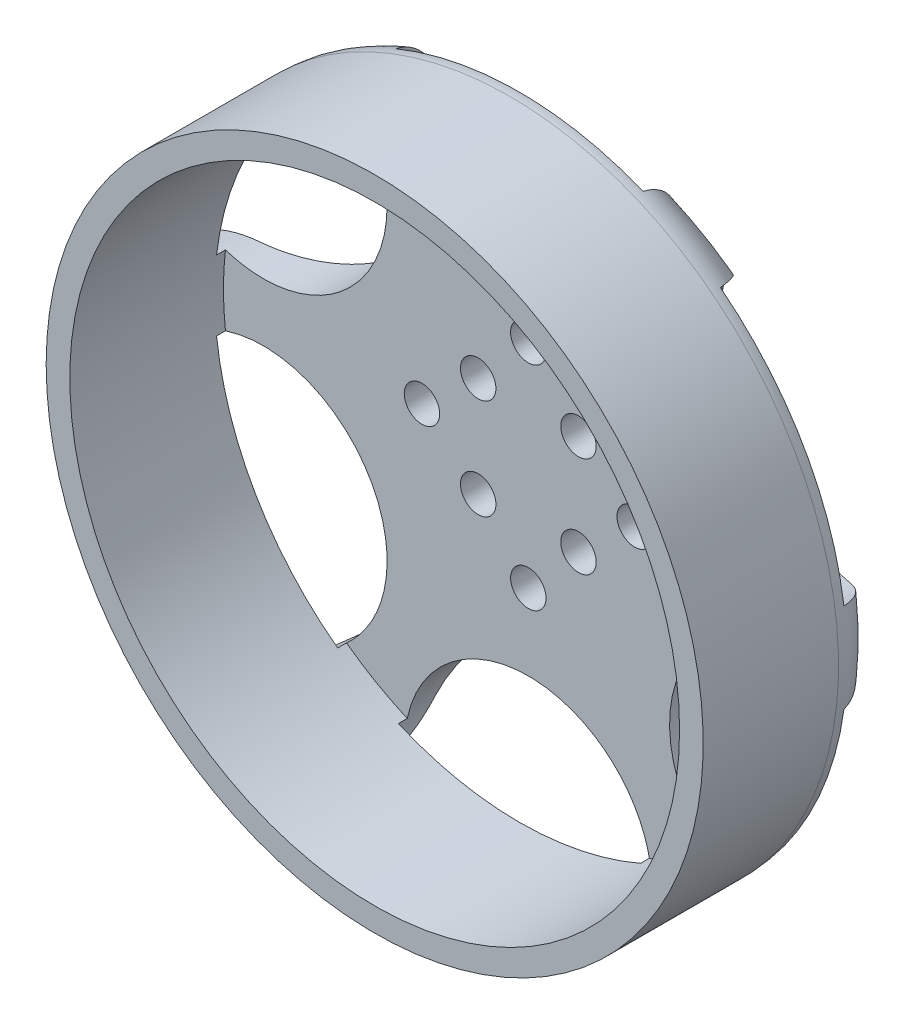
from build123d import *

# Parameters (mm, degrees)
SKETCH3_R          = 1.5
CUT_EXTRUDE1_DEPTH = 19.75
CIRPATTERN1_COUNT  = 4
CHAMFER1_SIZE      = 4.5
CHAMFER1_SIZE2     = 12.363648388
FILLET1_R          = 4
SKETCH4_R          = 25.8
CUT_EXTRUDE2_DEPTH = 13
SKETCH5_RX         = 10.458805078
SKETCH5_RY         = 10.321237489
CUT_EXTRUDE3_DEPTH = 6.5
CIRPATTERN2_COUNT  = 6


with BuildPart() as part:
    # Sketch2 → Revolve1 (revolve)
    with BuildSketch(Plane(origin=(0, 0, 0), x_dir=(1, 0, 0), z_dir=(0, 1, 0))):
        Polygon((0, 32), (-2, 32), (-2, 27), (-27.8, 27), (-27.8, 8.25), (0, 8.25), align=None)
    revolve(axis=Axis((0, 0, -88.99), (0, 0, 1)))

    # Sketch3 → Cut-Extrude1 (cut, through all)
    with BuildSketch(Plane(origin=(0, 0, -27), x_dir=(-1, 0, 0), z_dir=(0, 0, -1))):
        with Locations((0, 9)):
            Circle(SKETCH3_R)
        with Locations((4.242640687, 4.242640687)):
            Circle(SKETCH3_R)
    cut_extrude1 = extrude(amount=-CUT_EXTRUDE1_DEPTH, mode=Mode.SUBTRACT)

    # CirPattern1: Cut-Extrude1 ×4 about axis
    cirpattern1_axis = Axis((0, 0, 0), (0, 0, 1))
    for i in range(1, CIRPATTERN1_COUNT):
        add(cut_extrude1.rotate(cirpattern1_axis, i * 360 / CIRPATTERN1_COUNT), mode=Mode.SUBTRACT)

    # Chamfer1
    chamfer1_edges = [part.edges().sort_by_distance(p)[0] for p in [
        (27.8, 0, -27),
    ]]
    chamfer1_side = [part.faces().sort_by_distance(p)[0] for p in [
        (27.8, 0, -17.625),
    ]]
    chamfer(chamfer1_edges, length=CHAMFER1_SIZE, length2=CHAMFER1_SIZE2, reference=chamfer1_side[0])

    # Fillet1
    fillet1_edges = [part.edges().sort_by_distance(p)[0] for p in [
        (27.8, 0, -22.5),
    ]]
    fillet(fillet1_edges, radius=FILLET1_R)

    # Sketch4 → Cut-Extrude2 (cut)
    with BuildSketch(Plane.XY.offset(-8.25)):
        Circle(SKETCH4_R)
    extrude(amount=-CUT_EXTRUDE2_DEPTH, mode=Mode.SUBTRACT)

    # Sketch5 → Cut-Extrude3 (cut)
    with BuildSketch(Plane(origin=(0, 0, -27), x_dir=(-1, 0, 0), z_dir=(0, 0, -1))):
        with Locations(Location((0, 25.757589102), (0, 0, 180))):
            Ellipse(SKETCH5_RX, SKETCH5_RY)
    cut_extrude3 = extrude(amount=-CUT_EXTRUDE3_DEPTH, mode=Mode.SUBTRACT)

    # CirPattern2: Cut-Extrude3 ×6 about axis
    cirpattern2_axis = Axis((0, 0, -88.99), (0, 0, 1))
    for i in range(1, CIRPATTERN2_COUNT):
        add(cut_extrude3.rotate(cirpattern2_axis, i * 360 / CIRPATTERN2_COUNT), mode=Mode.SUBTRACT)


solid = part.part
